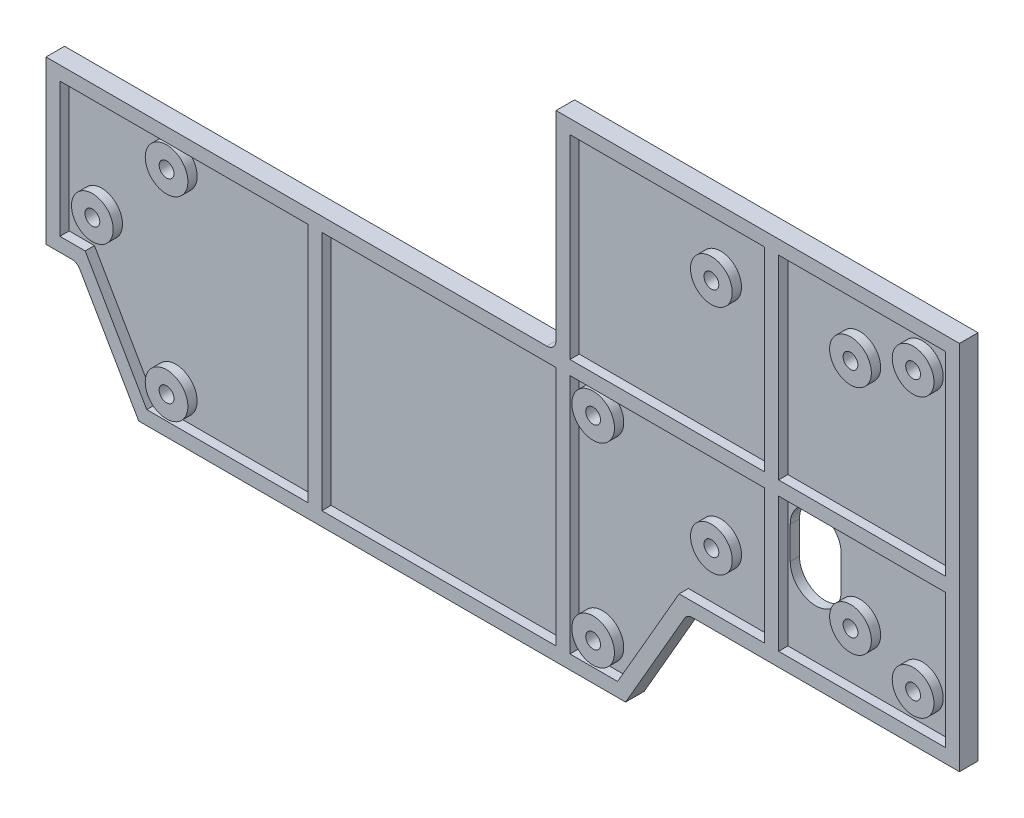
from build123d import *

# Parameters (mm, degrees)
ESQUISSE1_W             = 197
ESQUISSE1_H             = 80
ESQUISSE1_R             = 1.6
BOSS_EXTRU_1_DEPTH      = 2
ESQUISSE2_W             = 110
ESQUISSE2_H             = 45
ENL_V_MAT_EXTRU_1_DEPTH = 2
BOSS_EXTRU_6_DEPTH      = 2
BOSS_EXTRU_2_DEPTH      = 2
ESQUISSE4_W             = 3
ESQUISSE4_H             = 52
BOSS_EXTRU_3_DEPTH      = 2
ESQUISSE5_W             = 3
ESQUISSE5_H             = 74
BOSS_EXTRU_4_DEPTH      = 2
ESQUISSE6_R             = 4.5
ESQUISSE6_R_2           = 1.6
BOSS_EXTRU_5_DEPTH      = 2
ENL_V_MAT_EXTRU_2_DEPTH = 10
ESQUISSE9_R             = 1.6
ENL_V_MAT_EXTRU_3_DEPTH = 2
ESQUISSE10_R            = 4.6
ESQUISSE10_R_2          = 1.6
BOSS_EXTRU_7_DEPTH      = 2
CONG_14_R               = 2


with BuildPart() as part:
    # Esquisse1 → Boss.-Extru.1 (new body)
    with BuildSketch(Plane.XY):
        Rectangle(ESQUISSE1_W, ESQUISSE1_H)
        with Locations((-88.5, -30)):
            Circle(ESQUISSE1_R, mode=Mode.SUBTRACT)
        with Locations((88.5, 30)):
            Circle(ESQUISSE1_R, mode=Mode.SUBTRACT)
        with Locations((88.5, -30)):
            Circle(ESQUISSE1_R, mode=Mode.SUBTRACT)
        with Locations((-88.5, 30)):
            Circle(ESQUISSE1_R, mode=Mode.SUBTRACT)
        with Locations((45, 25)):
            Circle(ESQUISSE1_R, mode=Mode.SUBTRACT)
        with Locations((75, 25)):
            Circle(ESQUISSE1_R, mode=Mode.SUBTRACT)
        with Locations((45, -25)):
            Circle(ESQUISSE1_R, mode=Mode.SUBTRACT)
        with Locations((75, -25)):
            Circle(ESQUISSE1_R, mode=Mode.SUBTRACT)
    extrude(amount=BOSS_EXTRU_1_DEPTH)

    # Esquisse2 → Enlèv. mat.-Extru.1 (cut)
    with BuildSketch(Plane.XY.offset(2)):
        with Locations((-43.5, 17.5)):
            Rectangle(ESQUISSE2_W, ESQUISSE2_H)
    extrude(amount=-ENL_V_MAT_EXTRU_1_DEPTH, mode=Mode.SUBTRACT)

    # Esquisse8 → Boss.-Extru.6 (add)
    with BuildSketch(Plane.XY.offset(2)):
        Polygon((-91.779056191, -40), (-78.5, -63), (26.5, -63), (39.779056191, -40), align=None)
    extrude(amount=-BOSS_EXTRU_6_DEPTH)

    # Esquisse3 → Boss.-Extru.2 (add)
    with BuildSketch(Plane.XY.offset(2)):
        Polygon((98.5, 40), (11.5, 40), (11.5, -5), (-98.5, -5), (-98.5, -40), (-91.779056191, -40), (-78.5, -63), (26.5, -63), (39.779056191, -40), (98.5, -40), align=None)
        Polygon((95.5, 37), (14.5, 37), (14.5, -8), (-95.5, -8), (-95.5, -37), (-90.047005384, -37), (-76.767949192, -60), (24.767949192, -60), (38.047005384, -37), (95.5, -37), align=None, mode=Mode.SUBTRACT)
    extrude(amount=BOSS_EXTRU_2_DEPTH)

    # Esquisse4 → Boss.-Extru.3 (add)
    with BuildSketch(Plane.XY.offset(2)):
        Polygon((14.5, -5), (11.5, -5), (11.5, -60), (14.5, -60), (14.5, -8), (98.5, -8), (98.5, -5), align=None)
        with Locations((-40.5, -34)):
            Rectangle(ESQUISSE4_W, ESQUISSE4_H)
    extrude(amount=BOSS_EXTRU_3_DEPTH)

    # Esquisse5 → Boss.-Extru.4 (add)
    with BuildSketch(Plane.XY.offset(2)):
        with Locations((58, 0)):
            Rectangle(ESQUISSE5_W, ESQUISSE5_H)
    extrude(amount=BOSS_EXTRU_4_DEPTH)

    # Esquisse6 → Boss.-Extru.5 (add)
    with BuildSketch(Plane.XY.offset(2)):
        with Locations(Location((-88.5, -30, 0), (0, 0, 180))):
            Circle(ESQUISSE6_R)
        with Locations((-88.5, -30)):
            Circle(ESQUISSE6_R_2, mode=Mode.SUBTRACT)
        with Locations(Location((88.5, -30, 0), (0, 0, 180))):
            Circle(ESQUISSE6_R)
        with Locations((88.5, -30)):
            Circle(ESQUISSE6_R_2, mode=Mode.SUBTRACT)
        with Locations(Location((75, -25, 0), (0, 0, 180))):
            Circle(ESQUISSE6_R)
        with Locations((75, -25)):
            Circle(ESQUISSE6_R_2, mode=Mode.SUBTRACT)
        with Locations(Location((45, -25, 0), (0, 0, 180))):
            Circle(ESQUISSE6_R)
        with Locations((45, -25)):
            Circle(ESQUISSE6_R_2, mode=Mode.SUBTRACT)
        with Locations(Location((45, 25, 0), (0, 0, 180))):
            Circle(ESQUISSE6_R)
        with Locations((45, 25)):
            Circle(ESQUISSE6_R_2, mode=Mode.SUBTRACT)
        with Locations(Location((75, 25, 0), (0, 0, 180))):
            Circle(ESQUISSE6_R)
        with Locations((75, 25)):
            Circle(ESQUISSE6_R_2, mode=Mode.SUBTRACT)
        with Locations(Location((88.5, 30, 0), (0, 0, 180))):
            Circle(ESQUISSE6_R)
        with Locations((88.5, 30)):
            Circle(ESQUISSE6_R_2, mode=Mode.SUBTRACT)
    extrude(amount=BOSS_EXTRU_5_DEPTH)

    # Esquisse7 → Enlèv. mat.-Extru.2 (cut)
    with BuildSketch(Plane.XY.offset(2)):
        with BuildLine():
            Line((71, -14), (71, -21))
            ThreePointArc((71, -21), (65.5, -26.5), (60, -21))
            Line((60, -21), (60, -14))
            ThreePointArc((60, -14), (65.5, -8.5), (71, -14))
        make_face()
    extrude(amount=-ENL_V_MAT_EXTRU_2_DEPTH, mode=Mode.SUBTRACT)

    # Esquisse9 → Enlèv. mat.-Extru.3 (cut)
    with BuildSketch(Plane(origin=(0, 0, 0), x_dir=(-1, 0, 0), z_dir=(0, 0, -1))):
        with Locations((-19.5, -13)):
            Circle(ESQUISSE9_R)
        with Locations((-19.5, -55)):
            Circle(ESQUISSE9_R)
        with Locations((72.5, -13)):
            Circle(ESQUISSE9_R)
        with Locations((72.5, -55)):
            Circle(ESQUISSE9_R)
    extrude(amount=-ENL_V_MAT_EXTRU_3_DEPTH, mode=Mode.SUBTRACT)

    # Esquisse10 → Boss.-Extru.7 (add)
    with BuildSketch(Plane.XY.offset(2)):
        with Locations(Location((-72.5, -13, 0), (0, 0, 180))):
            Circle(ESQUISSE10_R)
        with Locations(Location((-72.5, -13, 0), (0, 0, 180))):
            Circle(ESQUISSE10_R_2, mode=Mode.SUBTRACT)
        with Locations(Location((-72.5, -55, 0), (0, 0, 180))):
            Circle(ESQUISSE10_R)
        with Locations(Location((-72.5, -55, 0), (0, 0, 180))):
            Circle(ESQUISSE10_R_2, mode=Mode.SUBTRACT)
        with Locations(Location((19.5, -13, 0), (0, 0, 180))):
            Circle(ESQUISSE10_R)
        with Locations(Location((19.5, -13, 0), (0, 0, 180))):
            Circle(ESQUISSE10_R_2, mode=Mode.SUBTRACT)
        with Locations(Location((19.5, -55, 0), (0, 0, 180))):
            Circle(ESQUISSE10_R)
        with Locations(Location((19.5, -55, 0), (0, 0, 180))):
            Circle(ESQUISSE10_R_2, mode=Mode.SUBTRACT)
    extrude(amount=BOSS_EXTRU_7_DEPTH)

    # Congé14
    cong_14_edges = [part.edges().sort_by_distance(p)[0] for p in [
        (11.5, -5, 2),
        (-91.779056191, -40, 2),
        (39.779056191, -40, 2),
    ]]
    fillet(cong_14_edges, radius=CONG_14_R)


solid = part.part
